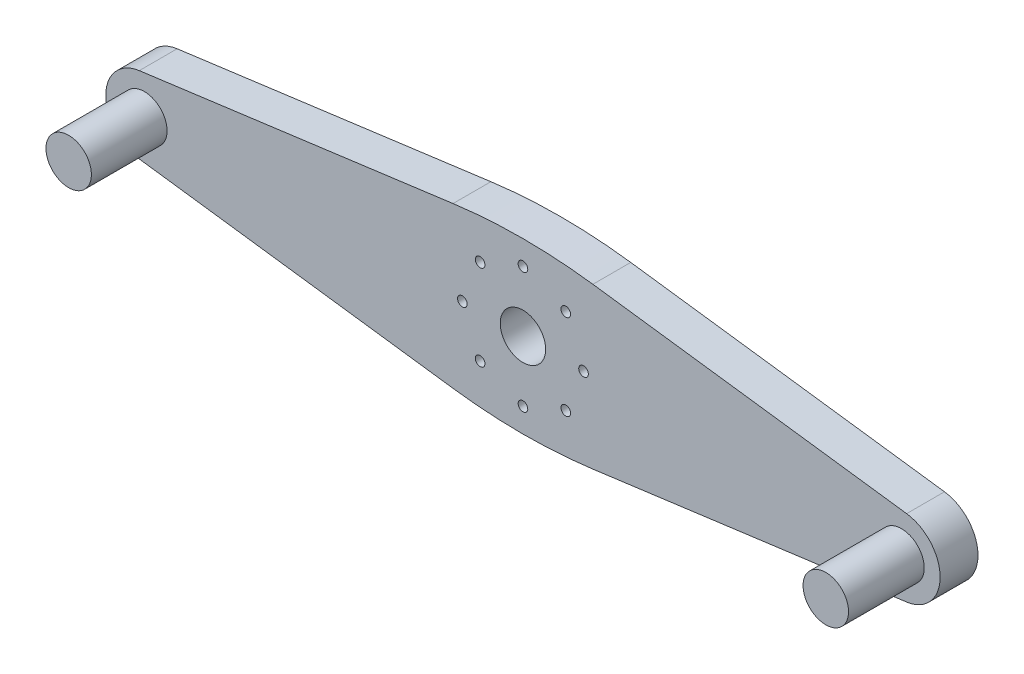
from build123d import *

# Parameters (mm, degrees)
SZKIC1_R                    = 3
SZKIC1_R_2                  = 0.635
DODANIE_WYCI_GNI_CIE1_DEPTH = 5
SZKIC1_2_R                  = 3
DODANIE_WYCI_GNI_CIE2_DEPTH = 15


with BuildPart() as part:
    # Szkic1 → Dodanie-wyci_gni_cie1 (new body)
    with BuildSketch(Plane.XY):
        with BuildLine():
            Line((-50.67287635, 5.055665151), (-9.235111676, 10.570763761))
            ThreePointArc((-9.235111676, 10.570763761), (0, 11.182632843), (9.235111676, 10.570763761))
            Line((9.235111676, 10.570763761), (50.67287635, 5.055665151))
            ThreePointArc((50.67287635, 5.055665151), (55.100246338, 0), (50.67287635, -5.055665151))
            Line((50.67287635, -5.055665151), (9.235111676, -10.570763761))
            ThreePointArc((9.235111676, -10.570763761), (0, -11.182632843), (-9.235111676, -10.570763761))
            Line((-9.235111676, -10.570763761), (-50.67287635, -5.055665151))
            ThreePointArc((-50.67287635, -5.055665151), (-55.100246338, 0), (-50.67287635, 5.055665151))
        make_face()
        Circle(SZKIC1_R, mode=Mode.SUBTRACT)
        with Locations((-5.656854249, 5.656854249)):
            Circle(SZKIC1_R_2, mode=Mode.SUBTRACT)
        with Locations((-8, 0)):
            Circle(SZKIC1_R_2, mode=Mode.SUBTRACT)
        with Locations((0, 8)):
            Circle(SZKIC1_R_2, mode=Mode.SUBTRACT)
        with Locations((5.656854249, 5.656854249)):
            Circle(SZKIC1_R_2, mode=Mode.SUBTRACT)
        with Locations((-50, 0)):
            Circle(SZKIC1_R, mode=Mode.SUBTRACT)
        with Locations((50, 0)):
            Circle(SZKIC1_R, mode=Mode.SUBTRACT)
        with Locations((8, 0)):
            Circle(SZKIC1_R_2, mode=Mode.SUBTRACT)
        with Locations((5.656854249, -5.656854249)):
            Circle(SZKIC1_R_2, mode=Mode.SUBTRACT)
        with Locations((0, -8)):
            Circle(SZKIC1_R_2, mode=Mode.SUBTRACT)
        with Locations((-5.656854249, -5.656854249)):
            Circle(SZKIC1_R_2, mode=Mode.SUBTRACT)
    extrude(amount=DODANIE_WYCI_GNI_CIE1_DEPTH)

    # Szkic1_2 → Dodanie-wyci_gni_cie2 (add)
    with BuildSketch(Plane.XY):
        with Locations((-50, 0)):
            Circle(SZKIC1_2_R)
        with Locations((50, 0)):
            Circle(SZKIC1_2_R)
    extrude(amount=DODANIE_WYCI_GNI_CIE2_DEPTH)


solid = part.part
